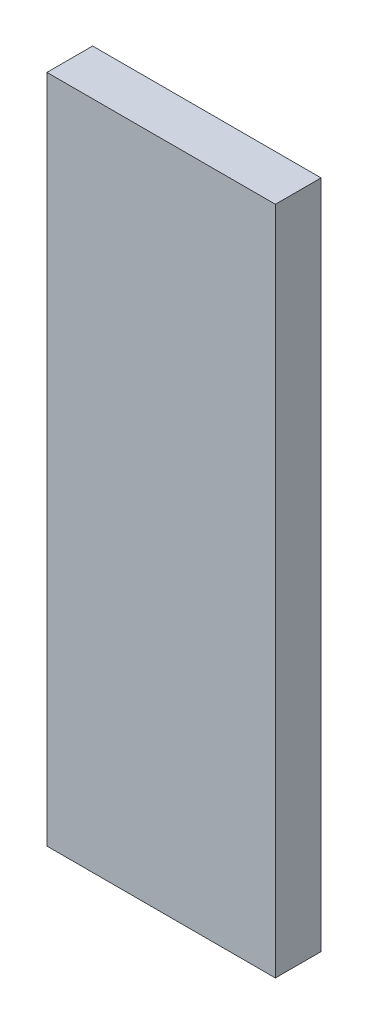
from build123d import *

# Parameters (mm, degrees)
SKETCH1_W           = 15
SKETCH1_H           = 44
BOSS_EXTRUDE1_DEPTH = 3


with BuildPart() as part:
    # Sketch1 → Boss-Extrude1 (new body)
    with BuildSketch(Plane.XY):
        Rectangle(SKETCH1_W, SKETCH1_H)
    extrude(amount=BOSS_EXTRUDE1_DEPTH)


solid = part.part
